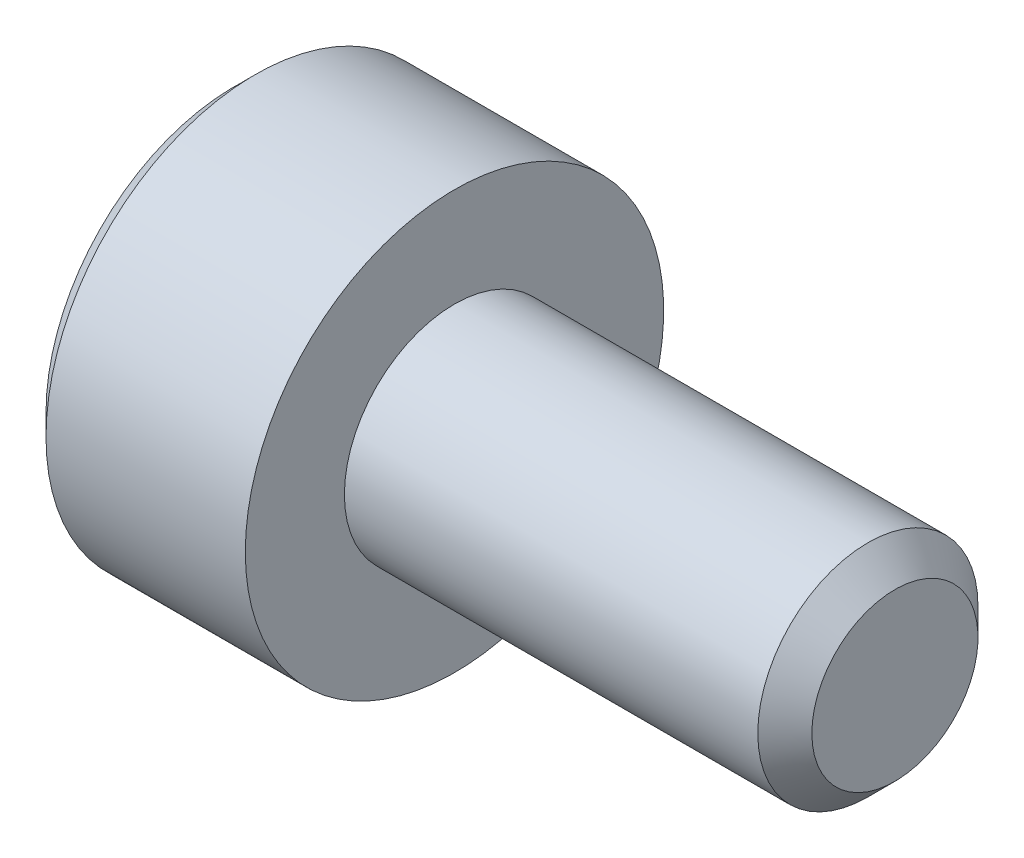
from build123d import *

# Parameters (mm, degrees)
CUT_EXTRUDE1_DEPTH = 0.8


with BuildPart() as part:
    # Sketch1 → Revolve1 (revolve)
    with BuildSketch(Plane.XY):
        Polygon((-2, 0), (-2, 1.71), (-1.81, 1.9), (0, 1.9), (0, 1), (3.7545, 1), (4, 0.7545), (4, 0), align=None)
    revolve(axis=Axis((4, 0, 0), (-1, 0, 0)))

    # Sketch2 → Cut-Extrude1 (cut)
    with BuildSketch(Plane(origin=(-2, 0, 0), x_dir=(0, 0, -1), z_dir=(1, 0, 0))):
        Polygon((-0.75, -0.433012702), (0, -0.866025404), (0.75, -0.433012702), (0.75, 0.433012702), (0, 0.866025404), (-0.75, 0.433012702), align=None)
    extrude(amount=CUT_EXTRUDE1_DEPTH, mode=Mode.SUBTRACT)


solid = part.part
